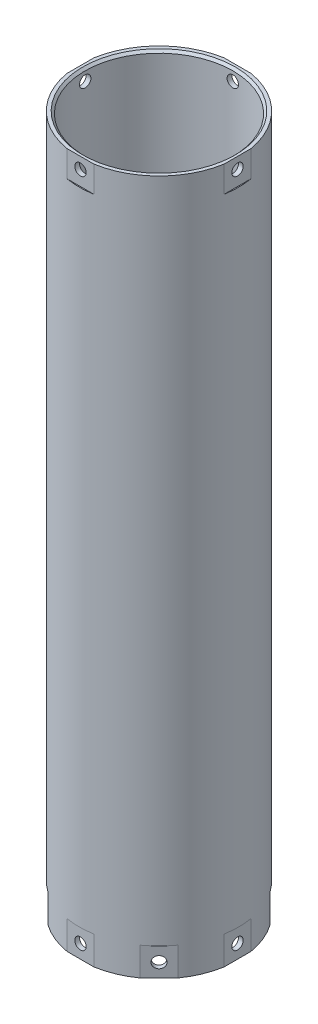
from build123d import *

# Parameters (mm, degrees)
F_1_4_0_25_DIAMETER_HOLE1_REACH  = 395.014
F_1_4_0_25_DIAMETER_HOLE1_BORE_R = 3.175
CIRPATTERN2_COUNT                = 4
CHAMFER1_SIZE                    = 1.27
CIRPATTERN1_COUNT                = 8
SKETCH7_W                        = 16.51
SKETCH7_H                        = 16.51
CUT_EXTRUDE1_DEPTH               = 0.635
SKETCH8_W                        = 16.51
SKETCH8_H                        = 16.51
CUT_EXTRUDE2_DEPTH               = 0.635
CIRPATTERN4_COUNT                = 8
CIRPATTERN5_COUNT                = 4


with BuildPart() as part:
    # Sketch2 → Revolve1 (revolve)
    with BuildSketch(Plane.XY, mode=Mode.PRIVATE) as revolve1_sk:
        Polygon((41.275, 0), (44.45, 0), (44.45, 387.858), (41.275, 387.858), (41.275, 193.929), align=None)
    revolve(revolve1_sk.sketch.rotate(Axis((0, 0, 0), (0, 1, 0)), 90), axis=Axis((0, 0, 0), (0, 1, 0)))

    # 1_4 _0.25_ Diameter Hole1 bore (on position points) → 1_4 _0.25_ Diameter Hole1 (cut, up to next)
    with BuildSketch(Plane(origin=(0, 7.62, -44.45), x_dir=(-1, 0, 0), z_dir=(0, 0, -1)), mode=Mode.PRIVATE) as f_1_4_0_25_diameter_hole1_sk1:
        Circle(F_1_4_0_25_DIAMETER_HOLE1_BORE_R)
    f_1_4_0_25_diameter_hole1_tool1 = extrude(f_1_4_0_25_diameter_hole1_sk1.sketch, amount=-F_1_4_0_25_DIAMETER_HOLE1_REACH, mode=Mode.PRIVATE) & part.part
    f_1_4_0_25_diameter_hole1 = f_1_4_0_25_diameter_hole1_tool1.solids().sort_by_distance((0, 7.62, -44.45))[0]
    add(f_1_4_0_25_diameter_hole1, mode=Mode.SUBTRACT)

    # Sketch6 → 1_4 _0.25_ Diameter Hole2 (revolve, cut)
    with BuildSketch(Plane(origin=(0, 381.508, -44.45), x_dir=(0, 1, 0), z_dir=(1, 0, 0))):
        Polygon((0, 0), (0, 5.209732465), (3.175, 3.302), (3.175, 0), align=None)
    f_1_4_0_25_diameter_hole2 = revolve(axis=Axis((0, 381.508, -50.8), (0, 0, 1)), mode=Mode.SUBTRACT)

    # CirPattern2: 1_4 _0.25_ Diameter Hole2 ×4 about axis
    cirpattern2_axis = Axis((0, -17.04721, 0), (0, 1, 0))
    for i in range(1, CIRPATTERN2_COUNT):
        add(f_1_4_0_25_diameter_hole2.rotate(cirpattern2_axis, i * 360 / CIRPATTERN2_COUNT), mode=Mode.SUBTRACT)

    # Chamfer1
    chamfer1_edges = [part.edges().sort_by_distance(p)[0] for p in [
        (0, 387.858, 41.275),
        (0, 0, 41.275),
    ]]
    chamfer(chamfer1_edges, length=CHAMFER1_SIZE)

    # CirPattern1: 1_4 _0.25_ Diameter Hole1 ×8 about axis
    cirpattern1_axis = Axis((0, -17.04721, 0), (0, 1, 0))
    for i in range(1, CIRPATTERN1_COUNT):
        add(f_1_4_0_25_diameter_hole1.rotate(cirpattern1_axis, i * 360 / CIRPATTERN1_COUNT), mode=Mode.SUBTRACT)

    # Sketch7 → Cut-Extrude1 (cut)
    with BuildSketch(Plane(origin=(44.45, 0, 0), x_dir=(0, 0, -1), z_dir=(1, 0, 0))):
        with Locations((0, 7.62)):
            Rectangle(SKETCH7_W, SKETCH7_H)
    cut_extrude1 = extrude(amount=-CUT_EXTRUDE1_DEPTH, mode=Mode.SUBTRACT)

    # Sketch8 → Cut-Extrude2 (cut)
    with BuildSketch(Plane(origin=(44.45, 0, 0), x_dir=(0, 0, -1), z_dir=(1, 0, 0))):
        with Locations((0, 381.508)):
            Rectangle(SKETCH8_W, SKETCH8_H)
    cut_extrude2 = extrude(amount=-CUT_EXTRUDE2_DEPTH, mode=Mode.SUBTRACT)

    # CirPattern4: Cut-Extrude1 ×8 about axis
    cirpattern4_axis = Axis((0, 0, 0), (0, 1, 0))
    for i in range(1, CIRPATTERN4_COUNT):
        add(cut_extrude1.rotate(cirpattern4_axis, i * 360 / CIRPATTERN4_COUNT), mode=Mode.SUBTRACT)

    # CirPattern5: Cut-Extrude2 ×4 about axis
    cirpattern5_axis = Axis((0, 0, 0), (0, 1, 0))
    for i in range(1, CIRPATTERN5_COUNT):
        add(cut_extrude2.rotate(cirpattern5_axis, i * 360 / CIRPATTERN5_COUNT), mode=Mode.SUBTRACT)


solid = part.part
